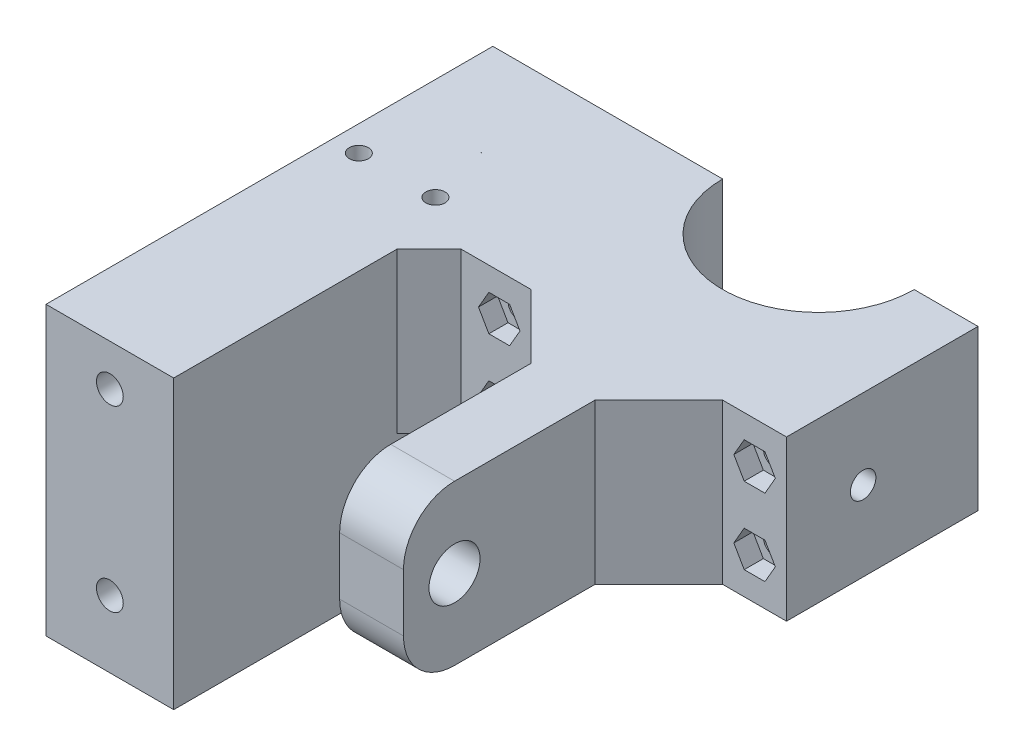
from build123d import *

# Parameters (mm, degrees)
BOSS_EXTRUDE1_DEPTH = 25
SKETCH2_R           = 4
CUT_EXTRUDE1_DEPTH  = 88.229582138
SKETCH3_R           = 1.6
CUT_EXTRUDE2_DEPTH  = 79.755553628
CUT_EXTRUDE3_DEPTH  = 3
FILLET2_R           = 8
CHAMFER2_SIZE       = 10
SKETCH5_W           = 30
SKETCH5_H           = 25
BOSS_EXTRUDE2_DEPTH = 26
SKETCH6_W           = 20.004484435
SKETCH6_H           = 25
BOSS_EXTRUDE3_DEPTH = 40
SKETCH7_W           = 10.4
SKETCH7_H           = 20.4
CUT_EXTRUDE4_DEPTH  = 23
SKETCH9_W           = 20.004484435
SKETCH9_H           = 40
SKETCH9_W_2         = 10.4
SKETCH9_H_2         = 20.4
BOSS_EXTRUDE4_DEPTH = 20
SKETCH10_R          = 2.1
CUT_EXTRUDE6_DEPTH  = 90.566948883
CHAMFER5_SIZE       = 5
SKETCH11_R          = 2
CUT_EXTRUDE7_DEPTH  = 112.736296699
SKETCH12_W          = 20.004484435
SKETCH12_H          = 20
SKETCH12_R          = 2.1
BOSS_EXTRUDE5_DEPTH = 30
SKETCH13_R          = 1.5
CUT_EXTRUDE8_DEPTH  = 103.986592973


with BuildPart() as part:
    # Sketch1 → Boss-Extrude1 (new body)
    with BuildSketch(Plane(origin=(0, 0, 0), x_dir=(1, 0, 0), z_dir=(0, 1, 0))):
        with BuildLine():
            Line((-13.972375691, -8), (-23.972375691, -8))
            Line((-23.972375691, -8), (-23.972375691, -38))
            Line((-23.972375691, -38), (-3.972375691, -38))
            Line((-3.972375691, -38), (-3.972375691, -78))
            Line((-3.972375691, -78), (6.027624309, -78))
            Line((6.027624309, -78), (6.027624309, -38))
            Line((6.027624309, -38), (26.027624309, -38))
            Line((26.027624309, -38), (26.027624309, -8))
            Line((26.027624309, -8), (16.027624309, -8))
            ThreePointArc((16.027624309, -8), (1.027624309, -23), (-13.972375691, -8))
        make_face()
    extrude(amount=BOSS_EXTRUDE1_DEPTH)

    # Sketch2 → Cut-Extrude1 (cut, through all)
    with BuildSketch(Plane.ZY.offset(3.972375691)):
        with Locations((70, 12.5)):
            Circle(SKETCH2_R)
    extrude(amount=-CUT_EXTRUDE1_DEPTH, mode=Mode.SUBTRACT)

    # Sketch3 → Cut-Extrude2 (cut, through all)
    with BuildSketch(Plane(origin=(0, 0, 8), x_dir=(-1, 0, 0), z_dir=(0, 0, -1))):
        with Locations((-21.027624309, 6.5)):
            Circle(SKETCH3_R)
        with Locations((-21.027624309, 18.5)):
            Circle(SKETCH3_R)
        with Locations((18.972375691, 6.5)):
            Circle(SKETCH3_R)
        with Locations((18.972375691, 18.5)):
            Circle(SKETCH3_R)
    extrude(amount=-CUT_EXTRUDE2_DEPTH, mode=Mode.SUBTRACT)

    # Sketch4 → Cut-Extrude3 (cut)
    with BuildSketch(Plane.XY.offset(38)):
        Polygon((24.277624309, 18.5), (22.652624309, 21.314582562), (19.402624309, 21.314582562), (17.777624309, 18.5), (19.402624309, 15.685417438), (22.652624309, 15.685417438), align=None)
        Polygon((24.277624309, 6.5), (22.652624309, 9.314582562), (19.402624309, 9.314582562), (17.777624309, 6.5), (19.402624309, 3.685417438), (22.652624309, 3.685417438), align=None)
        Polygon((-15.722375691, 18.5), (-17.347375691, 21.314582562), (-20.597375691, 21.314582562), (-22.222375691, 18.5), (-20.597375691, 15.685417438), (-17.347375691, 15.685417438), align=None)
        Polygon((-15.722375691, 6.5), (-17.347375691, 9.314582562), (-20.597375691, 9.314582562), (-22.222375691, 6.5), (-20.597375691, 3.685417438), (-17.347375691, 3.685417438), align=None)
    extrude(amount=-CUT_EXTRUDE3_DEPTH, mode=Mode.SUBTRACT)

    # Fillet2
    fillet2_edges = [part.edges().sort_by_distance(p)[0] for p in [
        (1.027624309, 0, 78),
        (1.027624309, 25, 78),
    ]]
    fillet(fillet2_edges, radius=FILLET2_R)

    # Chamfer2
    chamfer2_edges = [part.edges().sort_by_distance(p)[0] for p in [
        (6.027624309, 12.5, 38),
        (-3.972375691, 12.5, 38),
    ]]
    chamfer(chamfer2_edges, length=CHAMFER2_SIZE)

    # Sketch5 → Boss-Extrude2 (add)
    with BuildSketch(Plane.ZY.offset(23.972375691)):
        with Locations((23, 12.5)):
            Rectangle(SKETCH5_W, SKETCH5_H)
    extrude(amount=BOSS_EXTRUDE2_DEPTH)

    # Sketch6 → Boss-Extrude3 (add)
    with BuildSketch(Plane.XY.offset(38)):
        with Locations((-39.970133473, 12.5)):
            Rectangle(SKETCH6_W, SKETCH6_H)
    extrude(amount=BOSS_EXTRUDE3_DEPTH)

    # Sketch7 → Cut-Extrude4 (cut)
    with BuildSketch(Plane.XZ):
        with Locations((-39.970133474, 58)):
            Rectangle(SKETCH7_W, SKETCH7_H)
    extrude(amount=-CUT_EXTRUDE4_DEPTH, mode=Mode.SUBTRACT)

    # Sketch9 → Boss-Extrude4 (add)
    with BuildSketch(Plane.XZ):
        with Locations((-39.970133473, 58)):
            Rectangle(SKETCH9_W, SKETCH9_H)
        with Locations((-39.970133474, 58)):
            Rectangle(SKETCH9_W_2, SKETCH9_H_2, mode=Mode.SUBTRACT)
    extrude(amount=BOSS_EXTRUDE4_DEPTH)

    # Sketch10 → Cut-Extrude6 (cut, through all)
    with BuildSketch(Plane.XY.offset(78)):
        with Locations((-39.970133474, -9.5)):
            Circle(SKETCH10_R)
        with Locations((-39.970133474, 18.5)):
            Circle(SKETCH10_R)
    extrude(amount=-CUT_EXTRUDE6_DEPTH, mode=Mode.SUBTRACT)

    # Chamfer5
    chamfer5_edges = [part.edges().sort_by_distance(p)[0] for p in [
        (-29.967891256, 12.5, 38),
    ]]
    chamfer(chamfer5_edges, length=CHAMFER5_SIZE)

    # Sketch11 → Cut-Extrude7 (cut, through all)
    with BuildSketch(Plane(origin=(26.027624309, 0, 0), x_dir=(0, 0, -1), z_dir=(1, 0, 0))):
        with Locations((-26, 12.5)):
            Circle(SKETCH11_R)
    extrude(amount=-CUT_EXTRUDE7_DEPTH, mode=Mode.SUBTRACT)

    # Sketch12 → Boss-Extrude5 (add)
    with BuildSketch(Plane(origin=(0, 0, 38), x_dir=(-1, 0, 0), z_dir=(0, 0, -1))):
        with Locations((39.970133473, -10)):
            Rectangle(SKETCH12_W, SKETCH12_H)
        with Locations(Location((39.970133474, -9.5, 0), (0, 0, 180))):
            Circle(SKETCH12_R, mode=Mode.SUBTRACT)
    extrude(amount=BOSS_EXTRUDE5_DEPTH)

    # Sketch13 → Cut-Extrude8 (cut, through all)
    with BuildSketch(Plane.XZ.offset(20)):
        with Locations(Location((-33.970133474, 33, 0), (0, 0, 270))):
            Circle(SKETCH13_R)
        with Locations(Location((-45.970133474, 33, 0), (0, 0, 270))):
            Circle(SKETCH13_R)
    extrude(amount=-CUT_EXTRUDE8_DEPTH, mode=Mode.SUBTRACT)


solid = part.part
